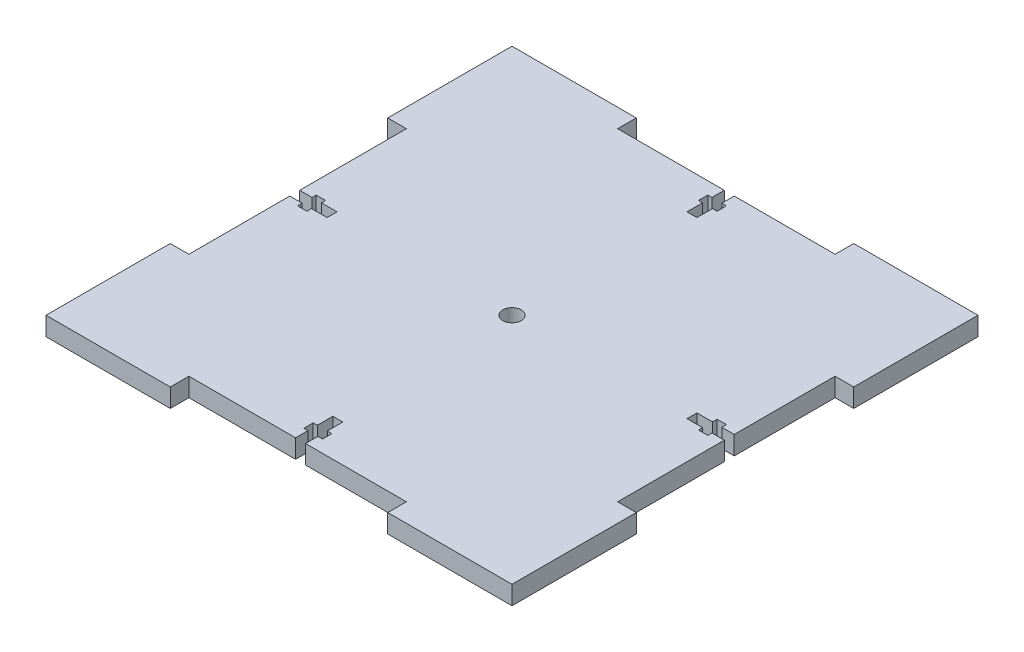
from build123d import *

# Parameters (mm, degrees)
SKETCH1_R           = 3
BOSS_EXTRUDE1_DEPTH = 6


with BuildPart() as part:
    # Sketch1 → Boss-Extrude1 (new body)
    with BuildSketch(Plane(origin=(0, 0, 0), x_dir=(1, 0, 0), z_dir=(0, 1, 0))):
        Polygon((75, -35), (69, -35), (69, -0.661610306), (65, -0.661610306), (65, -1.98375967), (62, -1.98375967), (62, -0.661610306), (57, -0.661610306), (57, 2.538389694), (62, 2.538389694), (62, 4.016764367), (65, 4.016764367), (65, 2.538389694), (69, 2.538389694), (69, 35), (75, 35), (75, 75), (35, 75), (35, 69), (2.538389694, 69), (2.538389694, 65), (4.016764367, 65), (4.016764367, 62), (2.538389694, 62), (2.538389694, 57), (-0.661610306, 57), (-0.661610306, 62), (-1.98375967, 62), (-1.98375967, 65), (-0.661610306, 65), (-0.661610306, 69), (-35, 69), (-35, 75), (-75, 75), (-75, 35), (-69, 35), (-69, 0.661610306), (-65, 0.661610306), (-65, 1.98375967), (-62, 1.98375967), (-62, 0.661610306), (-57, 0.661610306), (-57, -2.538389694), (-62, -2.538389694), (-62, -4.016764367), (-65, -4.016764367), (-65, -2.538389694), (-69, -2.538389694), (-69, -35), (-75, -35), (-75, -75), (-35, -75), (-35, -69), (-0.661610306, -69), (-0.661610306, -65), (-1.98375967, -65), (-1.98375967, -62), (-0.661610306, -62), (-0.661610306, -57), (2.538389694, -57), (2.538389694, -62), (4.016764367, -62), (4.016764367, -65), (2.538389694, -65), (2.538389694, -69), (35, -69), (35, -75), (75, -75), align=None)
        Circle(SKETCH1_R, mode=Mode.SUBTRACT)
    extrude(amount=BOSS_EXTRUDE1_DEPTH)


solid = part.part
